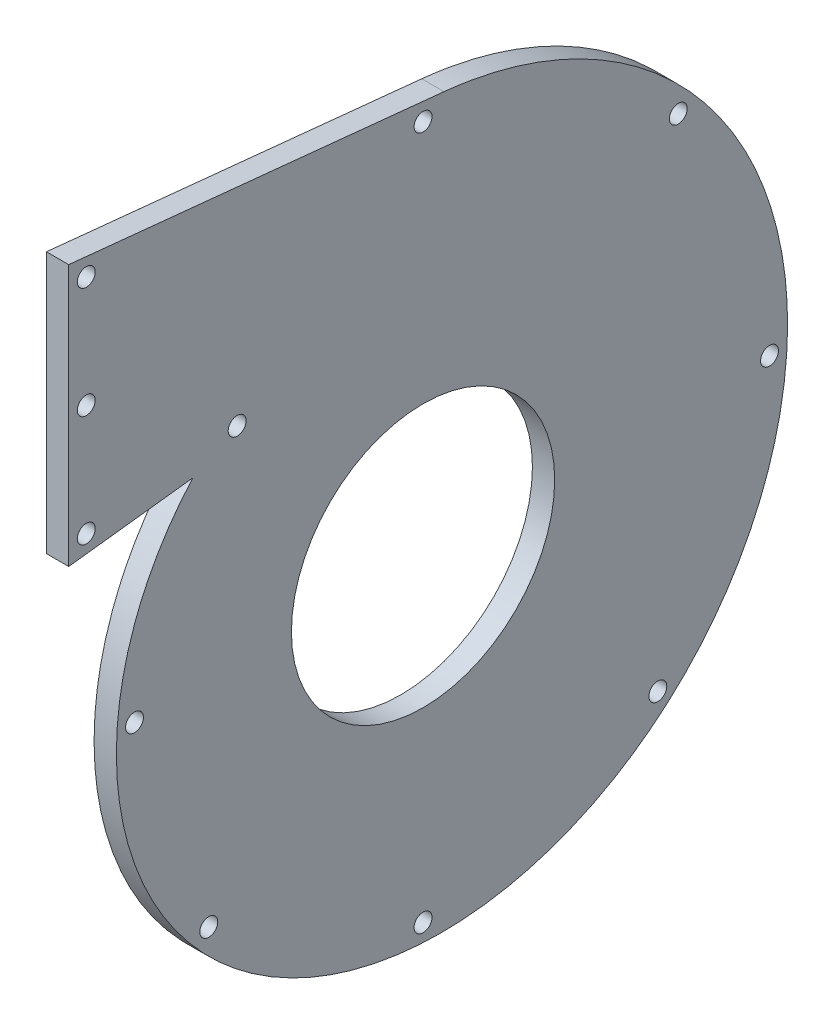
from build123d import *

# Parameters (mm, degrees)
BOSS_EXTRUDE1_DEPTH = 6.35
SKETCH11_R          = 2.55
CUT_EXTRUDE1_DEPTH  = 7.3500001
SKETCH12_R          = 37.5
CUT_EXTRUDE3_DEPTH  = 7.3500001


with BuildPart() as part:
    # Sketch10 → Boss-Extrude1 (new body)
    with BuildSketch(Plane(origin=(0, 0, 0), x_dir=(0, 0, -1), z_dir=(1, 0, 0))):
        with BuildLine():
            Line((-65.56933734, 52.009531221), (-100.935679824, 47.808985699))
            Line((-100.935679824, 47.808985699), (-100.935679824, 122.29075479))
            Line((-100.935679824, 122.29075479), (5.970340966, 111.513169224))
            add(Edge.make_bspline(
                [(5.970340966, 111.513169224), (9.050174513, 111.20267998), (15.195754527, 110.322198965), (27.224457069, 107.560584888), (41.672600889, 102.269141777), (57.583217011, 93.200335773), (76.34944741, 77.877389952), (94.274449289, 53.53377411), (104.843460982, 19.443777188), (103.677945005, -15.636484697), (91.289552438, -47.848309946), (69.405777179, -73.770277552), (40.739036605, -90.784845908), (8.654881454, -97.341351398), (-23.220610692, -93.091773694), (-51.414586087, -78.887047742), (-72.979776783, -56.641213756), (-85.804607758, -29.085280645), (-88.816261681, 0.571051967), (-83.191535024, 24.252063706), (-74.366432128, 41.075630131), (-68.698633198, 48.535069634), (-65.56933734, 52.009531221)],
                knots=[0.103071112, 0.103071112, 0.103071112, 0.103071112, 0.117085626, 0.13110014, 0.159129168, 0.187158196, 0.215187223, 0.271245279, 0.327303334, 0.38336139, 0.439419445, 0.495477501, 0.551535556, 0.607593612, 0.663651667, 0.719709723, 0.775767778, 0.831825834, 0.887883889, 0.943941945, 0.971970972, 1, 1, 1, 1], degree=3))
        make_face()
    extrude(amount=BOSS_EXTRUDE1_DEPTH)

    # Sketch11 → Cut-Extrude1 (cut, through all)
    with BuildSketch(Plane(origin=(6.35, 0, 0), x_dir=(0, 0, -1), z_dir=(1, 0, 0))):
        with Locations((-95.935679824, 116.761342324)):
            Circle(SKETCH11_R)
        with Locations((-95.935679824, 53.437991421)):
            Circle(SKETCH11_R)
        with Locations((-95.935679824, 85.099666873)):
            Circle(SKETCH11_R)
        with Locations((-52.956120261, 58.54277704)):
            Circle(SKETCH11_R)
        with Locations((0, -90.448962865)):
            Circle(SKETCH11_R)
        with Locations((-82.20247918, 0)):
            Circle(SKETCH11_R)
        with Locations((98.695882227, 0)):
            Circle(SKETCH11_R)
        with Locations((0, 107.089716811)):
            Circle(SKETCH11_R)
        with Locations((-61.03999449, -61.03999449)):
            Circle(SKETCH11_R)
        with Locations((66.874078846, -66.874078846)):
            Circle(SKETCH11_R)
        with Locations((72.70516699, 72.70516699)):
            Circle(SKETCH11_R)
    extrude(amount=-CUT_EXTRUDE1_DEPTH, mode=Mode.SUBTRACT)

    # Sketch12 → Cut-Extrude3 (cut, through all)
    with BuildSketch(Plane(origin=(0, 0, 0), x_dir=(0, 0, -1), z_dir=(1, 0, 0))):
        Circle(SKETCH12_R)
    extrude(amount=CUT_EXTRUDE3_DEPTH, mode=Mode.SUBTRACT)


solid = part.part
